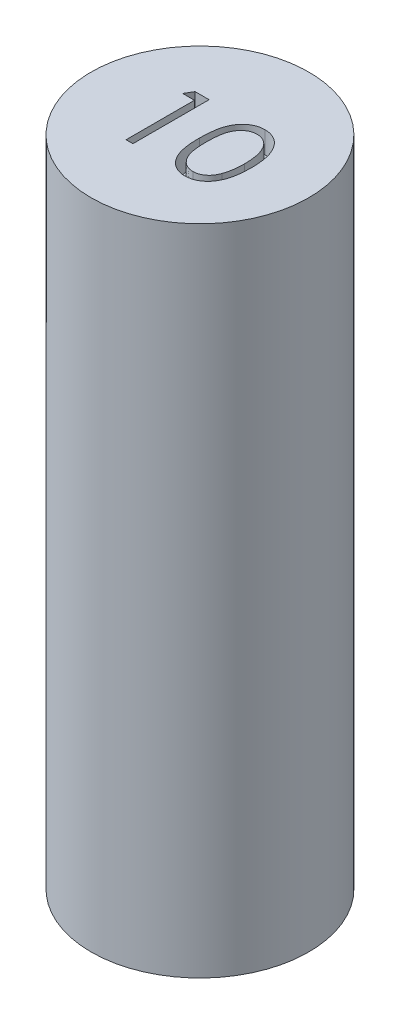
from build123d import *

# Parameters (mm, degrees)
SKETCH1_R           = 5
BOSS_EXTRUDE1_DEPTH = 30
CUT_EXTRUDE1_DEPTH  = 1


with BuildPart() as part:
    # Sketch1 → Boss-Extrude1 (new body)
    with BuildSketch(Plane(origin=(0, 0, 0), x_dir=(1, 0, 0), z_dir=(0, 1, 0))):
        Circle(SKETCH1_R)
    extrude(amount=BOSS_EXTRUDE1_DEPTH)

    # Sketch2 → Cut-Extrude1 (cut)
    with BuildSketch(Plane(origin=(0, 30, 0), x_dir=(1, 0, 0), z_dir=(0, 1, 0))):
        Polygon((-1.836629209, 1.610053215), (-1.189493792, 1.610053215), (-1.189493792, -1.889946785), (-1.503596356, -1.889946785), (-1.503596356, 1.251078856), (-2.042057895, 1.251078856), align=None)
        with BuildLine():
            add(Edge.make_bspline(
                [(0.111788259, -0.141349029), (0.112116277, -0.085251641), (0.112753457, 0.023718343), (0.119841878, 0.182502986), (0.131617221, 0.331463275), (0.147754593, 0.470606341), (0.167392574, 0.599968105), (0.19360806, 0.719202862), (0.223420863, 0.828862469), (0.257973309, 0.929304517), (0.296961098, 1.02188222), (0.339395358, 1.108307422), (0.386960153, 1.188449354), (0.436937066, 1.263587144), (0.491349137, 1.332490839), (0.548647928, 1.396133502), (0.611069804, 1.453044252), (0.676492812, 1.504890555), (0.745509277, 1.550340026), (0.816151943, 1.590372765), (0.888907049, 1.624572632), (0.963973232, 1.651463068), (1.04067579, 1.673673915), (1.119282856, 1.688862862), (1.19992422, 1.698419771), (1.254355655, 1.699333439), (1.281960535, 1.699796805)],
                knots=[0, 0, 0, 0, 0.000168282, 0.000326891, 0.000476705, 0.00061646, 0.000747059, 0.00086904, 0.000982494, 0.001087814, 0.001187428, 0.001283689, 0.001376399, 0.001466822, 0.001554203, 0.001639568, 0.001723424, 0.001807301, 0.001889751, 0.001971063, 0.002050735, 0.002130583, 0.002210036, 0.002290062, 0.002370508, 0.002453288, 0.002453288, 0.002453288, 0.002453288], degree=3))
            add(Edge.make_bspline(
                [(1.281960535, 1.699796805), (1.309796013, 1.69930899), (1.365152022, 1.698338879), (1.446992397, 1.689014936), (1.526942079, 1.673543813), (1.604660218, 1.651622839), (1.680785204, 1.624427162), (1.754721612, 1.590340045), (1.826928694, 1.550661177), (1.896258981, 1.5040373), (1.963473596, 1.452055024), (2.026921559, 1.393292355), (2.086608645, 1.328342636), (2.143283951, 1.257900772), (2.195339548, 1.180615687), (2.24491298, 1.097831577), (2.289285016, 1.008100712), (2.332019691, 0.912920245), (2.368906678, 0.809656586), (2.402172923, 0.698891825), (2.429051892, 0.579317638), (2.451441164, 0.451561393), (2.46878606, 0.31515391), (2.481418702, 0.170387594), (2.488091787, 0.017167204), (2.489348488, -0.087590645), (2.489993387, -0.141349029)],
                knots=[0, 0, 0, 0, 8.3481e-05, 0.000166017, 0.000246731, 0.000327534, 0.000408041, 0.000488986, 0.000571522, 0.000654944, 0.000739373, 0.000826202, 0.000914021, 0.001003809, 0.001097153, 0.001193347, 0.001293057, 0.001397277, 0.001506176, 0.001621751, 0.001744038, 0.001873599, 0.002010742, 0.002156422, 0.002309427, 0.002470709, 0.002470709, 0.002470709, 0.002470709], degree=3))
            add(Edge.make_bspline(
                [(2.489993387, -0.141349029), (2.489341803, -0.194872936), (2.488072217, -0.299162088), (2.48149351, -0.451693064), (2.468534879, -0.595691107), (2.452324891, -0.731501569), (2.429873928, -0.858559188), (2.402268761, -0.977303637), (2.371618439, -1.088247708), (2.333783644, -1.19048252), (2.292372934, -1.285434243), (2.247317738, -1.374101391), (2.199047912, -1.457267684), (2.146459167, -1.534267431), (2.090405754, -1.605646088), (2.029687965, -1.670143711), (1.96601738, -1.729314382), (1.898604964, -1.78196601), (1.828193413, -1.828050815), (1.756234336, -1.869264665), (1.681450952, -1.90249736), (1.605538, -1.931032401), (1.527409634, -1.952832853), (1.447163243, -1.967906708), (1.365207007, -1.978478557), (1.309805442, -1.979285037), (1.281960535, -1.979690375)],
                knots=[0, 0, 0, 0, 0.000160581, 0.000312886, 0.000457868, 0.000594226, 0.000723097, 0.000844701, 0.000959884, 0.001068125, 0.001171421, 0.001270505, 0.001366343, 0.001459687, 0.001550023, 0.00163832, 0.001725149, 0.001810562, 0.001894568, 0.001977446, 0.00205903, 0.002139777, 0.00222058, 0.002301983, 0.002384599, 0.00246808, 0.00246808, 0.00246808, 0.00246808], degree=3))
            add(Edge.make_bspline(
                [(1.281960535, -1.979690375), (1.254356421, -1.979224019), (1.199926496, -1.978304457), (1.119274071, -1.968790726), (1.040991627, -1.953495223), (0.964692873, -1.932078618), (0.889986358, -1.905863782), (0.817890071, -1.871710099), (0.747602388, -1.83237603), (0.679310832, -1.787580608), (0.614298671, -1.736258925), (0.552200065, -1.679494636), (0.494575046, -1.615871225), (0.440940951, -1.546393302), (0.389966862, -1.47170006), (0.343077489, -1.390771687), (0.299706635, -1.303929076), (0.260063144, -1.210611165), (0.224914481, -1.109456238), (0.193866773, -0.999307059), (0.169352615, -0.879191423), (0.14836966, -0.750074056), (0.131445277, -0.611400125), (0.119890952, -0.463094347), (0.112749637, -0.305249138), (0.112114566, -0.196979364), (0.111788259, -0.141349029)],
                knots=[0, 0, 0, 0, 8.278e-05, 0.000163226, 0.000243252, 0.00032184, 0.00040079, 0.000480463, 0.00056082, 0.000642298, 0.000725191, 0.000809047, 0.000894412, 0.000982346, 0.001072188, 0.001165503, 0.001262704, 0.001363236, 0.001469448, 0.001583766, 0.001706286, 0.001836995, 0.001976138, 0.002125253, 0.002283161, 0.002450041, 0.002450041, 0.002450041, 0.002450041], degree=3))
        make_face()
        with BuildLine():
            add(Edge.make_bspline(
                [(0.425890823, -0.139946785), (0.42601027, -0.186695484), (0.426242094, -0.277425529), (0.432298294, -0.40926879), (0.440548526, -0.532239118), (0.451189823, -0.646492655), (0.466992772, -0.751642667), (0.48469956, -0.84841235), (0.506247649, -0.936289587), (0.531742667, -1.015877398), (0.560781764, -1.088526467), (0.592487628, -1.156127682), (0.626548351, -1.219479618), (0.664667501, -1.278013227), (0.706182564, -1.331919391), (0.750155824, -1.382152223), (0.798228408, -1.426949204), (0.86473215, -1.480676059), (0.952528625, -1.536195193), (1.06314908, -1.584541283), (1.176817531, -1.614923739), (1.253968781, -1.618787495), (1.292477362, -1.620716016)],
                knots=[0, 0, 0, 0, 0.000140231, 0.000272162, 0.000395845, 0.00050998, 0.000616273, 0.00071473, 0.000805025, 0.000887508, 0.000965234, 0.00103957, 0.001111417, 0.001180842, 0.001248855, 0.001315406, 0.001380877, 0.0014457, 0.001571746, 0.00169106, 0.001806864, 0.001922266, 0.001922266, 0.001922266, 0.001922266], degree=3))
            add(Edge.make_bspline(
                [(1.292477362, -1.620716016), (1.331235033, -1.619118235), (1.408670357, -1.615925972), (1.521804152, -1.585127235), (1.631634422, -1.538657695), (1.717706362, -1.48371019), (1.783188906, -1.43138186), (1.830105896, -1.386767212), (1.873167944, -1.336811345), (1.914010019, -1.282912049), (1.951469095, -1.224039565), (1.985532232, -1.160476989), (2.01661558, -1.092047811), (2.034324626, -1.044278072), (2.043378804, -1.019854638)],
                knots=[0, 0, 0, 0, 0.000116044, 0.000231848, 0.000349318, 0.000472837, 0.000536674, 0.000600645, 0.000666733, 0.000734322, 0.000803367, 0.000875831, 0.000950509, 0.001028633, 0.001028633, 0.001028633, 0.001028633], degree=3))
            add(Edge.make_bspline(
                [(2.043378804, -1.019854638), (2.053930572, -0.988624898), (2.075355186, -0.925215134), (2.10296696, -0.826851482), (2.124712359, -0.723648718), (2.144275725, -0.616223601), (2.157628781, -0.5037839), (2.168376594, -0.386677516), (2.174707281, -0.264816154), (2.175492032, -0.182021163), (2.175890823, -0.139946785)],
                knots=[0, 0, 0, 0, 9.8886e-05, 0.00020078, 0.000306259, 0.000415188, 0.00052824, 0.000645799, 0.000767957, 0.000894177, 0.000894177, 0.000894177, 0.000894177], degree=3))
            add(Edge.make_bspline(
                [(2.175890823, -0.139946785), (2.175340634, -0.097879212), (2.174264346, -0.015586048), (2.170150359, 0.104932133), (2.159526784, 0.219399894), (2.147727665, 0.328310367), (2.130330444, 0.431060669), (2.111572637, 0.528510975), (2.086371425, 0.619453999), (2.05945165, 0.705313581), (2.028641254, 0.785114236), (1.99472552, 0.859228022), (1.958503761, 0.928012747), (1.919161521, 0.991279688), (1.877165838, 1.049312231), (1.831408289, 1.100946826), (1.783703916, 1.147783794), (1.71688673, 1.201246363), (1.62941244, 1.255758058), (1.520566793, 1.305923818), (1.407296149, 1.334732111), (1.330722695, 1.338793798), (1.292477362, 1.340822446)],
                knots=[0, 0, 0, 0, 0.000126219, 0.000246912, 0.000361616, 0.00047102, 0.00057545, 0.000674176, 0.000768567, 0.000858368, 0.000944043, 0.001024988, 0.001102772, 0.001177091, 0.00124833, 0.001317386, 0.001383826, 0.001448649, 0.001573728, 0.001692043, 0.001806995, 0.001921698, 0.001921698, 0.001921698, 0.001921698], degree=3))
            add(Edge.make_bspline(
                [(1.292477362, 1.340822446), (1.25376677, 1.338790999), (1.176275064, 1.334724405), (1.061827109, 1.306031151), (0.952122758, 1.256018186), (0.864879783, 1.201065813), (0.798015996, 1.148727502), (0.750933303, 1.103341048), (0.706787131, 1.053694793), (0.666119431, 0.999292878), (0.628030148, 0.940827511), (0.593049135, 0.877838746), (0.561531805, 0.810007382), (0.532447269, 0.737390947), (0.506874481, 0.657810002), (0.485780518, 0.570041009), (0.466293465, 0.473579117), (0.452498196, 0.367859609), (0.44023444, 0.253577456), (0.432353092, 0.130300137), (0.426221835, -0.001764243), (0.42600337, -0.092963402), (0.425890823, -0.139946785)],
                knots=[0, 0, 0, 0, 0.000116101, 0.000232413, 0.000351368, 0.000476447, 0.000540832, 0.000605795, 0.000672346, 0.000739935, 0.00080936, 0.000881545, 0.00095588, 0.001033607, 0.001116089, 0.001206384, 0.001304286, 0.001411174, 0.001526077, 0.001649061, 0.001781692, 0.001922624, 0.001922624, 0.001922624, 0.001922624], degree=3))
        make_face(mode=Mode.SUBTRACT)
    extrude(amount=-CUT_EXTRUDE1_DEPTH, mode=Mode.SUBTRACT)


solid = part.part
